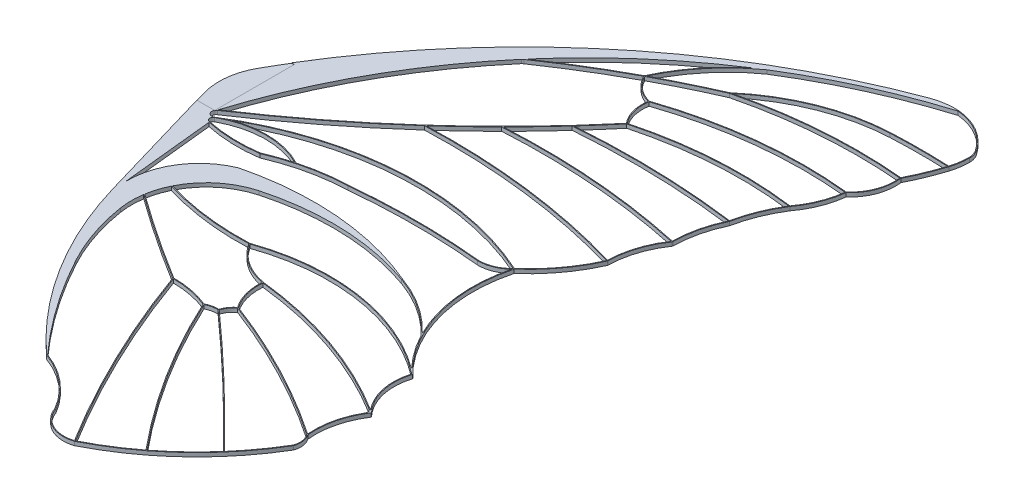
from build123d import *

# Parameters (mm, degrees)
RESSALTO_EXTRUS_O1_DEPTH = 2
ESBO_O3_W                = 13.5
ESBO_O3_H                = 41.75
CORTE_EXTRUS_O2_DEPTH    = 0.2


with BuildPart() as part:
    # Esbo_o1 → Ressalto-extrus_o1 (new body)
    with BuildSketch(Plane(origin=(0, 0, 0), x_dir=(1, 0, 0), z_dir=(0, 1, 0))):
        with BuildLine():
            Line((16.890636414, -92.871950666), (-2.891885916, -25.331386579))
            ThreePointArc((-2.891885916, -25.331386579), (-4.004170085, -12.373640544), (0, 0))
            ThreePointArc((0, 0), (80.341988523, 97.826401656), (189.397159866, 162.105555232))
            ThreePointArc((189.397159866, 162.105555232), (196.305976757, 163.870755082), (203.432149719, 164.126372503))
            ThreePointArc((203.432149719, 164.126372503), (216.132997815, 159.854580332), (225.805048795, 150.58035904))
            ThreePointArc((225.805048795, 150.58035904), (226.92415432, 148.202079294), (227.308114084, 145.601851107))
            ThreePointArc((227.308114084, 145.601851107), (226.936116515, 140.796582456), (225.828988219, 136.105819626))
            ThreePointArc((225.828988219, 136.105819626), (222.53357195, 127.064851642), (218.517613108, 118.320084919))
            ThreePointArc((218.517613108, 118.320084919), (217.157138995, 106.918422119), (210.665701384, 97.446883587))
            ThreePointArc((210.665701384, 97.446883587), (207.81407221, 86.384811826), (202.212176332, 76.428909901))
            ThreePointArc((202.212176332, 76.428909901), (196.683977717, 65.597702677), (193.192392505, 53.949318131))
            ThreePointArc((193.192392505, 53.949318131), (193.186037336, 53.925638832), (193.176832614, 53.902915046))
            ThreePointArc((193.176832614, 53.902915046), (189.041723719, 42.177149), (187.495240153, 29.840167866))
            ThreePointArc((187.495240153, 29.840167866), (187.463240561, 29.647364474), (187.376766076, 29.472095295))
            ThreePointArc((187.376766076, 29.472095295), (181.421355488, 17.384501121), (179.237322945, 4.087627428))
            ThreePointArc((179.237322945, 4.087627428), (179.232638679, 4.047550287), (179.220005433, 4.009229005))
            ThreePointArc((179.220005433, 4.009229005), (170.345122282, -11.218617872), (158.407910237, -24.186032419))
            ThreePointArc((158.407910237, -24.186032419), (158.838253644, -64.171647637), (179.513294894, -98.399958861))
            ThreePointArc((179.513294894, -98.399958861), (179.568845143, -98.494180052), (179.566523634, -98.60353303))
            ThreePointArc((179.566523634, -98.60353303), (179.033051629, -113.383903181), (185.969624565, -126.446364285))
            ThreePointArc((185.969624565, -126.446364285), (186.089619632, -126.716123165), (186.018022228, -127.002553753))
            ThreePointArc((186.018022228, -127.002553753), (180.544757753, -139.671656891), (179.579203123, -153.438664648))
            ThreePointArc((179.579203123, -153.438664648), (181.188239019, -157.584851871), (180.732122887, -162.008857192))
            ThreePointArc((180.732122887, -162.008857192), (155.03526296, -193.949101447), (121.431473842, -217.428734539))
            ThreePointArc((121.431473842, -217.428734539), (121.423131136, -217.432766567), (121.414649078, -217.436496537))
            ThreePointArc((121.414649078, -217.436496537), (109.339932134, -216.703217601), (101.317198447, -207.649365854))
            ThreePointArc((101.317198447, -207.649365854), (90.053250325, -194.317508541), (74.924632392, -185.614643143))
            ThreePointArc((74.924632392, -185.614643143), (39.509715195, -143.24681252), (16.890636414, -92.871950666))
        make_face()
        with BuildLine():
            Line((11.85931196, -37.464698075), (16.890636414, -86.132821))
            ThreePointArc((16.890636414, -86.132821), (23.057242833, -64.675979535), (40.261886529, -50.448424731))
            ThreePointArc((40.261886529, -50.448424731), (87.670250354, -46.538605901), (133.842737694, -57.981553802))
            ThreePointArc((133.842737694, -57.981553802), (149.854946418, -65.924493525), (163.541497745, -77.420555131))
            ThreePointArc((163.541497745, -77.420555131), (155.983137797, -51.598831019), (157.848232778, -24.758345519))
            ThreePointArc((157.848232778, -24.758345519), (151.973262614, -28.636570967), (145.058243072, -29.955059416))
            ThreePointArc((145.058243072, -29.955059416), (111.045550918, -28.261906009), (77.032122973, -29.940213308))
            ThreePointArc((77.032122973, -29.940213308), (57.801285112, -32.389959226), (39.361189646, -38.372371707))
            ThreePointArc((39.361189646, -38.372371707), (25.569939965, -39.139925167), (11.85931196, -37.464698075))
        make_face(mode=Mode.SUBTRACT)
        with BuildLine():
            ThreePointArc((11.070359275, -33.894012744), (10.253925603, -35.789100329), (11.879579324, -37.059994062))
            ThreePointArc((11.879579324, -37.059994062), (25.524465377, -38.738184329), (39.251467246, -37.984090401))
            ThreePointArc((39.251467246, -37.984090401), (45.854920305, -35.402452346), (52.618625636, -33.275779462))
            ThreePointArc((52.618625636, -33.275779462), (31.766860679, -28.367665282), (11.070359275, -33.894012744))
        make_face(mode=Mode.SUBTRACT)
        with BuildLine():
            ThreePointArc((202.714101827, 163.712950676), (167.471686306, 150.296359156), (134.231187047, 132.489001443))
            ThreePointArc((134.231187047, 132.489001443), (117.587042911, 117.093961509), (105.366397335, 97.997087152))
            ThreePointArc((105.366397335, 97.997087152), (119.960236596, 105.436275442), (134.832810466, 112.301274588))
            ThreePointArc((134.832810466, 112.301274588), (162.992204891, 129.355762587), (195.166849247, 136.327083543))
            ThreePointArc((195.166849247, 136.327083543), (210.329945011, 136.70097858), (225.494110918, 136.373346207))
            ThreePointArc((225.494110918, 136.373346207), (226.552562533, 140.93374904), (226.908114084, 145.601851107))
            ThreePointArc((226.908114084, 145.601851107), (226.541225779, 148.086469034), (225.471877456, 150.359006698))
            ThreePointArc((225.471877456, 150.359006698), (215.925826131, 159.51241094), (203.390434406, 163.728553659))
            ThreePointArc((203.390434406, 163.728553659), (203.051769924, 163.742347016), (202.714101827, 163.712950676))
        make_face(mode=Mode.SUBTRACT)
        with BuildLine():
            ThreePointArc((39.414410112, -134.60371344), (55.710509097, -160.996401051), (75.061191815, -185.238675693))
            ThreePointArc((75.061191815, -185.238675693), (90.32477142, -194.023121535), (101.682640282, -207.482028103))
            ThreePointArc((101.682640282, -207.482028103), (109.381253065, -216.277627559), (121.038273811, -217.140805352))
            ThreePointArc((121.038273811, -217.140805352), (94.455943613, -168.678582058), (73.078069491, -117.706100627))
            ThreePointArc((73.078069491, -117.706100627), (50.023709071, -102.94081443), (27.530070276, -87.334616156))
            ThreePointArc((27.530070276, -87.334616156), (27.068868432, -93.446906914), (27.564899418, -99.556469804))
            ThreePointArc((27.564899418, -99.556469804), (32.024240404, -117.575549791), (39.414410112, -134.60371344))
        make_face(mode=Mode.SUBTRACT)
        with BuildLine():
            ThreePointArc((55.949990062, -55.478367997), (95.05027781, -50.955008797), (133.708809753, -58.358466666))
            ThreePointArc((133.708809753, -58.358466666), (149.927402921, -66.450957854), (163.72457307, -78.205500545))
            ThreePointArc((163.72457307, -78.205500545), (163.984765643, -78.494020984), (164.23916715, -78.787660375))
            ThreePointArc((164.23916715, -78.787660375), (169.918511042, -87.993064481), (176.841349297, -96.30382391))
            ThreePointArc((176.841349297, -96.30382391), (128.956486326, -76.690746726), (77.454382768, -81.707341939))
            ThreePointArc((77.454382768, -81.707341939), (54.053212131, -80.755434548), (31.132626071, -75.942156085))
            ThreePointArc((31.132626071, -75.942156085), (41.348809985, -63.051320172), (55.949990062, -55.478367997))
        make_face(mode=Mode.SUBTRACT)
        with BuildLine():
            ThreePointArc((8.646375466, -29.892212669), (7.936541731, -32.891512454), (10.884162093, -33.792177396))
            ThreePointArc((10.884162093, -33.792177396), (83.286903321, -10.270827271), (158.195344978, -23.840507352))
            ThreePointArc((158.195344978, -23.840507352), (169.975242199, -11.046105684), (178.761046703, 3.962969299))
            ThreePointArc((178.761046703, 3.962969299), (124.842337918, 15.064533704), (69.841232126, 17.377594644))
            ThreePointArc((69.841232126, 17.377594644), (40.102456108, -7.368908744), (8.646375466, -29.892212669))
        make_face(mode=Mode.SUBTRACT)
        with BuildLine():
            ThreePointArc((65.873725431, 73.521849244), (65.512554625, 73.261919505), (65.163327011, 72.986151676))
            ThreePointArc((65.163327011, 72.986151676), (31.751463387, 24.609289931), (8.608266137, -29.43759531))
            ThreePointArc((8.608266137, -29.43759531), (68.727790014, 16.919047723), (121.642967981, 71.355060116))
            ThreePointArc((121.642967981, 71.355060116), (117.855262612, 78.759779692), (117.42803317, 87.066045938))
            ThreePointArc((117.42803317, 87.066045938), (110.028306452, 90.798172973), (104.841521177, 97.262071658))
            ThreePointArc((104.841521177, 97.262071658), (85.034977645, 85.921559119), (65.873725431, 73.521849244))
        make_face(mode=Mode.SUBTRACT)
        with BuildLine():
            ThreePointArc((104.7762631, 97.681029789), (115.574418721, 115.248461285), (130.105906511, 129.878932118))
            ThreePointArc((130.105906511, 129.878932118), (96.177838084, 104.381251589), (66.264337516, 74.274308482))
            ThreePointArc((66.264337516, 74.274308482), (85.206415837, 86.494114614), (104.7762631, 97.681029789))
        make_face(mode=Mode.SUBTRACT)
        with BuildLine():
            ThreePointArc((135.713472408, 112.526537053), (163.518917342, 129.134060421), (195.18595438, 135.927540062))
            ThreePointArc((195.18595438, 135.927540062), (210.276471462, 136.300892078), (225.368164637, 135.97856519))
            ThreePointArc((225.368164637, 135.97856519), (222.128079781, 127.130596632), (218.195023717, 118.568133932))
            ThreePointArc((218.195023717, 118.568133932), (176.701785201, 118.994028297), (135.713472408, 112.526537053))
        make_face(mode=Mode.SUBTRACT)
        with BuildLine():
            ThreePointArc((135.00518658, 111.940090583), (176.305917901, 118.563594016), (218.132560685, 118.172238852))
            ThreePointArc((218.132560685, 118.172238852), (216.767534509, 107.01891476), (210.409374715, 97.754264805))
            ThreePointArc((210.409374715, 97.754264805), (163.467402557, 97.622974649), (117.64681506, 87.422986968))
            ThreePointArc((117.64681506, 87.422986968), (110.323017386, 91.074314456), (105.194171334, 97.451237144))
            ThreePointArc((105.194171334, 97.451237144), (119.956691333, 104.989862866), (135.00518658, 111.940090583))
        make_face(mode=Mode.SUBTRACT)
        with BuildLine():
            ThreePointArc((121.975723187, 71.579960434), (118.238216137, 78.876060323), (117.832890254, 87.063718319))
            ThreePointArc((117.832890254, 87.063718319), (163.48468813, 97.222424933), (210.25288905, 97.368547957))
            ThreePointArc((210.25288905, 97.368547957), (207.439428108, 86.525283804), (201.957251989, 76.756062495))
            ThreePointArc((201.957251989, 76.756062495), (161.711502037, 78.108067884), (121.975723187, 71.579960434))
        make_face(mode=Mode.SUBTRACT)
        with BuildLine():
            ThreePointArc((201.712469543, 76.384918569), (196.290949467, 65.692265225), (192.837884131, 54.211757605))
            ThreePointArc((192.837884131, 54.211757605), (151.026567478, 57.488322955), (109.101297358, 56.395708613))
            ThreePointArc((109.101297358, 56.395708613), (115.62650859, 63.726667144), (122.015582584, 71.176571043))
            ThreePointArc((122.015582584, 71.176571043), (161.60786351, 77.700482874), (201.712469543, 76.384918569))
        make_face(mode=Mode.SUBTRACT)
        with BuildLine():
            ThreePointArc((187.097186474, 29.949540999), (139.348979985, 36.992165146), (91.086670247, 37.481283297))
            ThreePointArc((91.086670247, 37.481283297), (100.008574142, 46.616810225), (108.708987791, 55.963522143))
            ThreePointArc((108.708987791, 55.963522143), (150.759305033, 57.095075342), (192.697680535, 53.826703734))
            ThreePointArc((192.697680535, 53.826703734), (188.632596088, 42.184795574), (187.097186474, 29.949540999))
        make_face(mode=Mode.SUBTRACT)
        with BuildLine():
            ThreePointArc((70.307334653, 17.795498029), (125.114397795, 15.433974602), (178.842127699, 4.355978275))
            ThreePointArc((178.842127699, 4.355978275), (181.056540683, 17.556695855), (186.958653653, 29.570339432))
            ThreePointArc((186.958653653, 29.570339432), (139.066008112, 36.613044124), (90.660333167, 37.055558956))
            ThreePointArc((90.660333167, 37.055558956), (80.610470403, 27.291705844), (70.307334653, 17.795498029))
        make_face(mode=Mode.SUBTRACT)
        with BuildLine():
            ThreePointArc((53.184593307, -33.120484), (34.997673911, -28.037667048), (16.344111956, -30.977682642))
            ThreePointArc((16.344111956, -30.977682642), (86.294442644, -10.497166778), (157.8926845, -24.142387796))
            ThreePointArc((157.8926845, -24.142387796), (152.04587989, -28.173512381), (145.079823263, -29.555230382))
            ThreePointArc((145.079823263, -29.555230382), (111.043124536, -27.861905479), (77.00571445, -29.540870677))
            ThreePointArc((77.00571445, -29.540870677), (64.991382888, -30.640116345), (53.184593307, -33.120484))
        make_face(mode=Mode.SUBTRACT)
        with BuildLine():
            ThreePointArc((77.385630644, -82.110602151), (53.928434843, -81.142970387), (30.954862617, -76.306512457))
            ThreePointArc((30.954862617, -76.306512457), (28.904488661, -81.471516217), (27.604076284, -86.874314091))
            ThreePointArc((27.604076284, -86.874314091), (27.640126359, -86.915622588), (27.682018255, -86.950993041))
            ThreePointArc((27.682018255, -86.950993041), (50.20912985, -102.583681626), (73.29906303, -117.372417034))
            ThreePointArc((73.29906303, -117.372417034), (83.327149533, -118.337154453), (92.986045613, -121.200537717))
            ThreePointArc((92.986045613, -121.200537717), (96.035057019, -120.070400422), (99.274681475, -119.790196472))
            ThreePointArc((99.274681475, -119.790196472), (100.839320134, -116.575545142), (103.329588684, -114.010269354))
            ThreePointArc((103.329588684, -114.010269354), (99.325868559, -105.523547237), (98.476067628, -96.178384559))
            ThreePointArc((98.476067628, -96.178384559), (86.442113829, -91.376407189), (77.385630644, -82.110602151))
        make_face(mode=Mode.SUBTRACT)
        with BuildLine():
            ThreePointArc((77.796430253, -82.0108729), (130.390825581, -77.316445759), (178.842177575, -98.308695665))
            ThreePointArc((178.842177575, -98.308695665), (179.042636723, -98.592893915), (179.048514046, -98.940626531))
            ThreePointArc((179.048514046, -98.940626531), (178.557910182, -113.090704042), (184.838939896, -125.779835275))
            ThreePointArc((184.838939896, -125.779835275), (143.48611956, -105.890223927), (98.718726209, -95.813871314))
            ThreePointArc((98.718726209, -95.813871314), (86.794460768, -91.13013492), (77.796430253, -82.0108729))
        make_face(mode=Mode.SUBTRACT)
        with BuildLine():
            ThreePointArc((103.734386544, -113.889234988), (99.732427529, -105.493744387), (98.872883702, -96.233014243))
            ThreePointArc((98.872883702, -96.233014243), (143.098520561, -106.179072223), (183.998274189, -125.724945907))
            ThreePointArc((183.998274189, -125.724945907), (184.88113455, -126.943403006), (184.664770288, -128.432451905))
            ThreePointArc((184.664770288, -128.432451905), (179.978340813, -140.338043697), (179.145908385, -153.10569005))
            ThreePointArc((179.145908385, -153.10569005), (142.589295312, -131.287701646), (103.734386544, -113.889234988))
        make_face(mode=Mode.SUBTRACT)
        with BuildLine():
            ThreePointArc((99.649253017, -119.933520799), (101.18300434, -116.782199542), (103.6372122, -114.280183841))
            ThreePointArc((103.6372122, -114.280183841), (142.598272069, -131.743297777), (179.242488543, -153.655073914))
            ThreePointArc((179.242488543, -153.655073914), (180.78822356, -157.611813736), (180.367828424, -161.838911403))
            ThreePointArc((180.367828424, -161.838911403), (173.27117969, -172.652799603), (165.237327428, -182.789851396))
            ThreePointArc((165.237327428, -182.789851396), (133.00300151, -150.777649689), (99.649253017, -119.933520799))
        make_face(mode=Mode.SUBTRACT)
        with BuildLine():
            ThreePointArc((93.258837749, -121.508897014), (96.210985678, -120.441238679), (99.340524238, -120.194135217))
            ThreePointArc((99.340524238, -120.194135217), (132.717797326, -151.058354618), (164.973783051, -183.092614136))
            ThreePointArc((164.973783051, -183.092614136), (155.156655203, -193.286781209), (144.390735312, -202.473293628))
            ThreePointArc((144.390735312, -202.473293628), (116.188479484, -163.656017033), (93.258837749, -121.508897014))
        make_face(mode=Mode.SUBTRACT)
        with BuildLine():
            ThreePointArc((121.414649077, -216.988884436), (133.074913856, -210.37840662), (144.073565841, -202.71747677))
            ThreePointArc((144.073565841, -202.71747677), (115.816888065, -163.816723913), (92.849554804, -121.576813702))
            ThreePointArc((92.849554804, -121.576813702), (83.369797481, -118.753083082), (73.527113878, -117.772862193))
            ThreePointArc((73.527113878, -117.772862193), (94.877808499, -168.632444086), (121.414649077, -216.988884436))
        make_face(mode=Mode.SUBTRACT)
    extrude(amount=RESSALTO_EXTRUS_O1_DEPTH)

    # Esbo_o3 → Corte-extrus_o2 (cut)
    with BuildSketch(Plane(origin=(0, 2, 0), x_dir=(1, 0, 0), z_dir=(0, 1, 0))):
        with Locations((1.25, -9.755)):
            Rectangle(ESBO_O3_W, ESBO_O3_H)
    extrude(amount=-CORTE_EXTRUS_O2_DEPTH, mode=Mode.SUBTRACT)


solid = part.part
